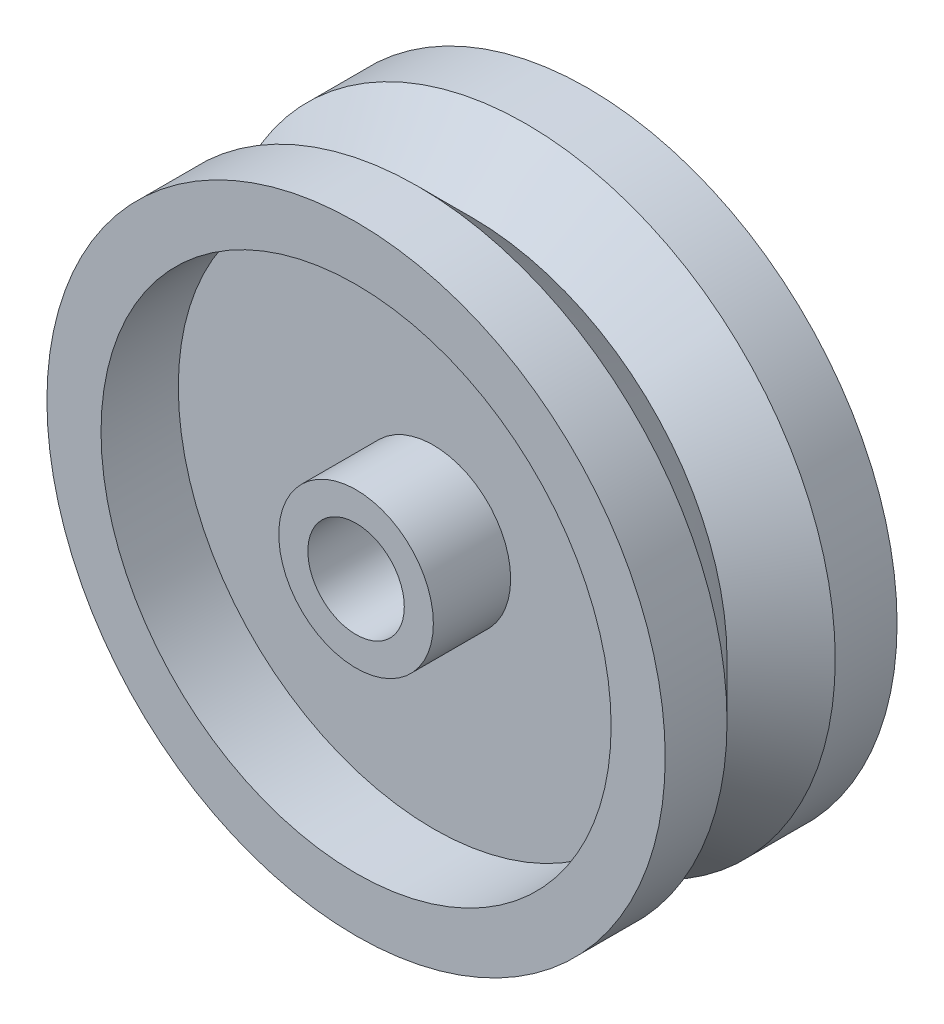
from build123d import *


with BuildPart() as part:
    # Sketch1 → Revolve1 (revolve)
    with BuildSketch(Plane(origin=(0, 0, 0), x_dir=(0, 0, -1), z_dir=(1, 0, 0))):
        Polygon((0, 0), (4, 0), (7.5, 3.5), (11, 0), (15, 0), (15, 3.5), (10, 3.5), (10, 15), (15, 15), (15, 16.88), (0, 16.88), (0, 15), (5, 15), (5, 3.5), (0, 3.5), align=None)
    revolve(axis=Axis((0, 20, 8.781522249), (0, 0, -1)))


solid = part.part
